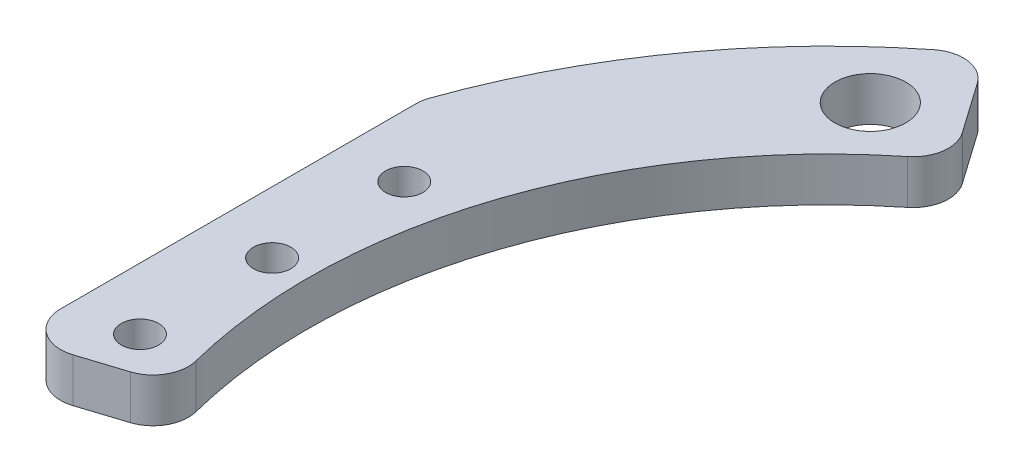
from build123d import *

# Parameters (mm, degrees)
SKETCH1_R               = 4.025
SKETCH1_R_2             = 2.125
BOSS_EXTRUDE1_DEPTH     = 2.5
SKETCH2_W               = 28.904595792
SKETCH2_H               = 55.332112
CUT_EXTRUDE1_DEPTH      = 1
CUT_EXTRUDE1_DEPTH_BACK = 6
FILLET1_R               = 4


with BuildPart() as part:
    # Sketch1 → Boss-Extrude1 (new body, symmetric)
    with BuildSketch(Plane(origin=(0, 0, 0), x_dir=(1, 0, 0), z_dir=(0, 1, 0))):
        with BuildLine():
            Line((-42.512697833, 60.569551121), (-33.895259083, 48.291939407))
            ThreePointArc((-33.895259083, 48.291939407), (-55.932258345, 18.777179671), (-56.169167779, -18.056151058))
            Line((-56.169167779, -18.056151058), (-70.449464672, -22.646697938))
            ThreePointArc((-70.449464672, -22.646697938), (-70.152324026, 23.55103891), (-42.512697833, 60.569551121))
        make_face()
        with Locations((-44.329902671, 49.233344688)):
            Circle(SKETCH1_R, mode=Mode.SUBTRACT)
        with Locations((-63, 0)):
            Circle(SKETCH1_R_2, mode=Mode.SUBTRACT)
        with Locations((-63, -15)):
            Circle(SKETCH1_R_2, mode=Mode.SUBTRACT)
        with Locations((-63, 15)):
            Circle(SKETCH1_R_2, mode=Mode.SUBTRACT)
    extrude(amount=BOSS_EXTRUDE1_DEPTH, both=True)

    # Sketch2 → Cut-Extrude1 (cut, two sides)
    with BuildSketch(Plane(origin=(0, 2.5, 0), x_dir=(1, 0, 0), z_dir=(0, 1, 0))) as cut_extrude1_sk:
        with Locations((-84.452297896, 0)):
            Rectangle(SKETCH2_W, SKETCH2_H)
    extrude(amount=CUT_EXTRUDE1_DEPTH, mode=Mode.SUBTRACT)
    extrude(cut_extrude1_sk.sketch, amount=-CUT_EXTRUDE1_DEPTH_BACK, mode=Mode.SUBTRACT)

    # Fillet1
    fillet1_edges = [part.edges().sort_by_distance(p)[0] for p in [
        (-70, 0, 22.502212941),
        (-70, 0, -24),
        (-42.512697833, 0, -60.569551121),
        (-33.895259083, 0, -48.291939407),
        (-56.169167779, 0, 18.056151058),
    ]]
    fillet(fillet1_edges, radius=FILLET1_R)


solid = part.part
